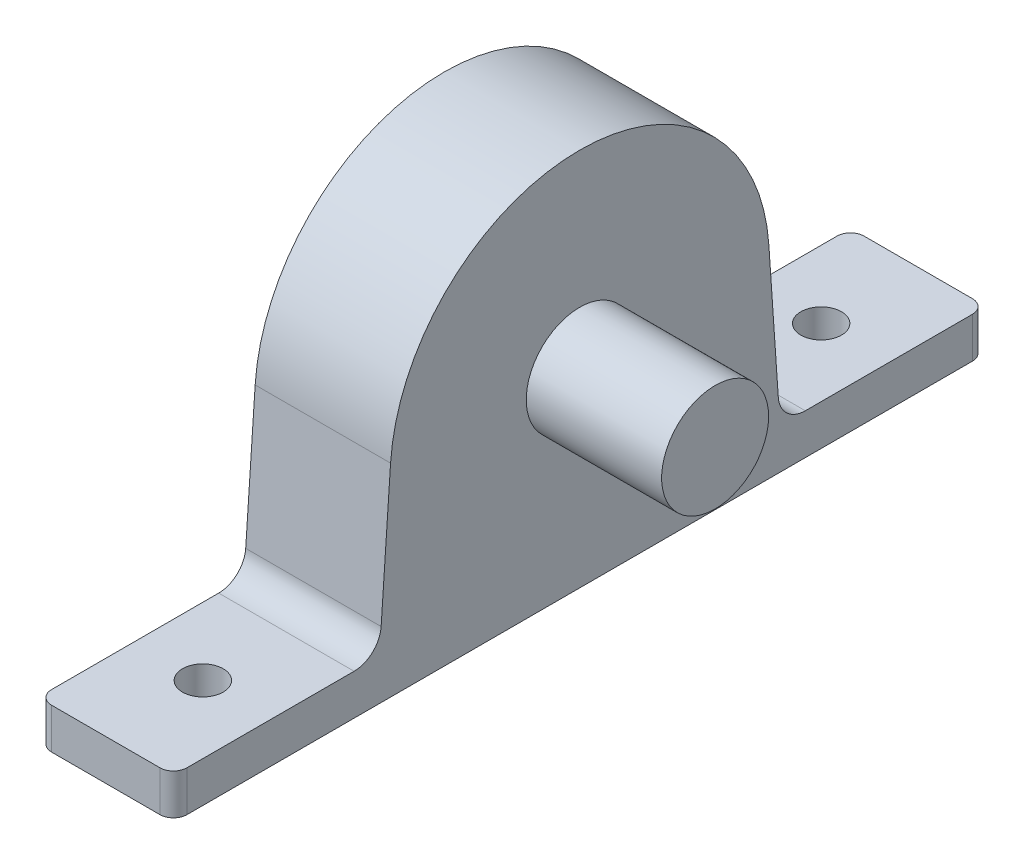
from build123d import *

# Parameters (mm, degrees)
BOSS_EXTRUDE1_DEPTH = 10
SKETCH2_R           = 3.95
BOSS_EXTRUDE2_DEPTH = 10
BOSS_EXTRUDE3_DEPTH = 10
SKETCH5_W           = 10
SKETCH5_H           = 60
BOSS_EXTRUDE4_DEPTH = 3
FILLET1_R           = 1
FILLET2_R           = 2
SKETCH7_R           = 1.5
CUT_EXTRUDE1_DEPTH  = 3


with BuildPart() as part:
    # Sketch1 → Boss-Extrude1 (new body)
    with BuildSketch(Plane(origin=(0, 0, 0), x_dir=(0, 0, -1), z_dir=(1, 0, 0))):
        with BuildLine():
            Line((-15, 0), (15, 0))
            Line((15, 0), (9.520917343, 17.058125725))
            ThreePointArc((9.520917343, 17.058125725), (0, 24), (-9.520917343, 17.058125725))
            Line((-9.520917343, 17.058125725), (-15, 0))
        make_face()
    extrude(amount=BOSS_EXTRUDE1_DEPTH)

    # Sketch2 → Boss-Extrude2 (add)
    with BuildSketch(Plane(origin=(10, 0, 0), x_dir=(0, 0, -1), z_dir=(1, 0, 0))):
        with Locations((0, 14)):
            Circle(SKETCH2_R)
    extrude(amount=BOSS_EXTRUDE2_DEPTH)

    # Sketch4 → Boss-Extrude3 (add)
    with BuildSketch(Plane(origin=(10, 0, 0), x_dir=(0, 0, -1), z_dir=(1, 0, 0))):
        with BuildLine():
            Line((9.520917343, 17.058125725), (15, 0))
            Line((15, 0), (13.966745843, 14.964370546))
            ThreePointArc((13.966745843, 14.964370546), (0, 28), (-13.966745843, 14.964370546))
            Line((-13.966745843, 14.964370546), (-15, 0))
            Line((-15, 0), (-9.520917343, 17.058125725))
            ThreePointArc((-9.520917343, 17.058125725), (0, 24), (9.520917343, 17.058125725))
        make_face()
    extrude(amount=-BOSS_EXTRUDE3_DEPTH)

    # Sketch5 → Boss-Extrude4 (add)
    with BuildSketch(Plane.XZ):
        with Locations((5, 0)):
            Rectangle(SKETCH5_W, SKETCH5_H)
    extrude(amount=-BOSS_EXTRUDE4_DEPTH)

    # Fillet1
    fillet1_edges = [part.edges().sort_by_distance(p)[0] for p in [
        (10, 1.5, 30),
        (0, 1.5, -30),
        (0, 1.5, 30),
        (10, 1.5, -30),
    ]]
    fillet(fillet1_edges, radius=FILLET1_R)

    # Fillet2
    fillet2_edges = [part.edges().sort_by_distance(p)[0] for p in [
        (5, 3, -14.792857143),
        (5, 3, 14.792857143),
    ]]
    fillet(fillet2_edges, radius=FILLET2_R)

    # Sketch7 → Cut-Extrude1 (cut)
    with BuildSketch(Plane(origin=(0, 3, 0), x_dir=(1, 0, 0), z_dir=(0, 1, 0))):
        with Locations((5, 22.829761905)):
            Circle(SKETCH7_R)
        with Locations((5, -22.829761905)):
            Circle(SKETCH7_R)
    extrude(amount=-CUT_EXTRUDE1_DEPTH, mode=Mode.SUBTRACT)


solid = part.part
